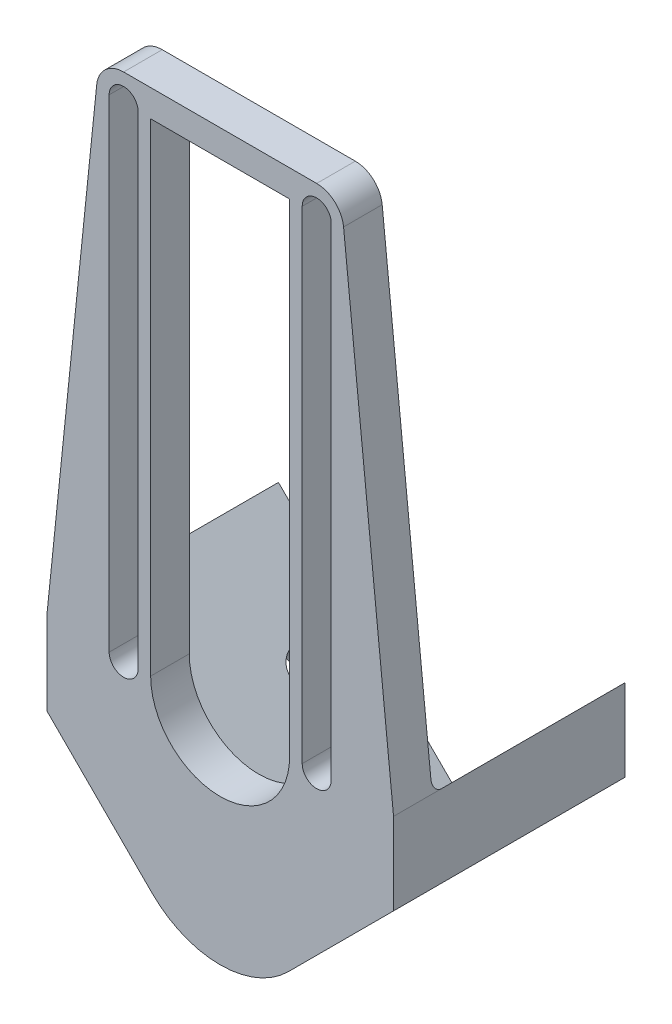
from build123d import *

# Parameters (mm, degrees)
SALIENTE_EXTRUIR1_DEPTH = 20
SALIENTE_EXTRUIR2_DEPTH = 4
REDONDEO1_R             = 1
REDONDEO2_R             = 10
CROQUIS3_R              = 1.8
CORTAR_EXTRUIR1_DEPTH   = 6
CROQUIS4_R              = 1.8
CORTAR_EXTRUIR2_DEPTH   = 6
CROQUIS5_R              = 3.2
CORTAR_EXTRUIR3_DEPTH   = 4
CROQUIS6_R              = 3.2
CORTAR_EXTRUIR4_DEPTH   = 4


with BuildPart() as part:
    # Croquis2 → Saliente-Extruir1 (new body)
    with BuildSketch(Plane.XY):
        Polygon((0, 0), (-17.960512242, 17.960512242), (-17.960512242, 9.475230868), (0, -8.485281374), align=None)
        Polygon((0, -8.485281374), (0, 0), (17.960512242, 17.960512242), (17.960512242, 9.475230868), align=None)
    extrude(amount=-SALIENTE_EXTRUIR1_DEPTH)

    # Croquis2_3 → Saliente-Extruir2 (add)
    with BuildSketch(Plane.XY):
        Polygon((0, 0), (-17.960512242, 17.960512242), (-17.960512242, 9.475230868), (0, -8.485281374), align=None)
        with BuildLine():
            Line((-17.960512242, 17.960512242), (0, 0))
            Line((0, 0), (0, 10.760512242))
            ThreePointArc((0, 10.760512242), (-5.091168825, 12.869343418), (-7.2, 17.960512242))
            ThreePointArc((-7.2, 17.960512242), (-10, 15.160512242), (-12.8, 17.960512242))
            Line((-12.8, 17.960512242), (-12.8, 67.960512242))
            ThreePointArc((-12.8, 67.960512242), (-12.796319785, 68.104024126), (-12.785288814, 68.247158756))
            Line((-12.785288814, 68.247158756), (-17.960512242, 17.960512242))
        make_face()
        with BuildLine():
            Line((0, 10.760512242), (0, 0))
            Line((0, 0), (17.960512242, 17.960512242))
            Line((17.960512242, 17.960512242), (12.785288814, 68.247158756))
            ThreePointArc((12.785288814, 68.247158756), (12.796319785, 68.104024126), (12.8, 67.960512242))
            Line((12.8, 67.960512242), (12.8, 17.960512242))
            ThreePointArc((12.8, 17.960512242), (10, 15.160512242), (7.2, 17.960512242))
            ThreePointArc((7.2, 17.960512242), (5.091168825, 12.869343418), (0, 10.760512242))
        make_face()
        Polygon((0, -8.485281374), (0, 0), (17.960512242, 17.960512242), (17.960512242, 9.475230868), align=None)
        with BuildLine():
            Line((12.8, 67.960512242), (12.8, 17.960512242))
            ThreePointArc((12.8, 17.960512242), (10, 15.160512242), (7.2, 17.960512242))
            Line((7.2, 17.960512242), (7.2, 67.960512242))
            ThreePointArc((7.2, 67.960512242), (10, 70.760512242), (12.8, 67.960512242))
        make_face()
        with BuildLine():
            ThreePointArc((11.5, 67.960512242), (10, 69.460512242), (8.5, 67.960512242))
            Line((8.5, 67.960512242), (8.5, 17.960512242))
            ThreePointArc((8.5, 17.960512242), (10, 16.460512242), (11.5, 17.960512242))
            Line((11.5, 17.960512242), (11.5, 67.960512242))
        make_face(mode=Mode.SUBTRACT)
        with BuildLine():
            ThreePointArc((-12.8, 67.960512242), (-10, 70.760512242), (-7.2, 67.960512242))
            Line((-7.2, 67.960512242), (-7.2, 17.960512242))
            ThreePointArc((-7.2, 17.960512242), (-10, 15.160512242), (-12.8, 17.960512242))
            Line((-12.8, 17.960512242), (-12.8, 67.960512242))
        make_face()
        with BuildLine():
            Line((-11.5, 67.960512242), (-11.5, 17.960512242))
            ThreePointArc((-11.5, 17.960512242), (-10, 16.460512242), (-8.5, 17.960512242))
            Line((-8.5, 17.960512242), (-8.5, 67.960512242))
            ThreePointArc((-8.5, 67.960512242), (-10, 69.460512242), (-11.5, 67.960512242))
        make_face(mode=Mode.SUBTRACT)
        with BuildLine():
            ThreePointArc((-10, 70.760512242), (-8.020101013, 69.940411229), (-7.2, 67.960512242))
            Line((-7.2, 67.960512242), (0, 67.960512242))
            Line((0, 67.960512242), (0, 70.760512242))
            Line((0, 70.760512242), (-10, 70.760512242))
        make_face()
        with BuildLine():
            ThreePointArc((7.2, 67.960512242), (8.020101013, 69.940411229), (10, 70.760512242))
            Line((10, 70.760512242), (0, 70.760512242))
            Line((0, 70.760512242), (0, 67.960512242))
            Line((0, 67.960512242), (7.2, 67.960512242))
        make_face()
    extrude(amount=SALIENTE_EXTRUIR2_DEPTH)

    # Redondeo1
    redondeo1_edges = [part.edges().sort_by_distance(p)[0] for p in [
        (-8.980256121, 8.980256121, 0),
        (8.980256121, 8.980256121, 0),
    ]]
    fillet(redondeo1_edges, radius=REDONDEO1_R)

    # Redondeo2
    redondeo2_edges = [part.edges().sort_by_distance(p)[0] for p in [
        (0, -8.485281374, -8),
    ]]
    fillet(redondeo2_edges, radius=REDONDEO2_R)

    # Croquis3 → Cortar-Extruir1 (cut)
    with BuildSketch(Plane(origin=(0, 0, 0), x_dir=(0, 0, -1), z_dir=(0.707106781, 0.707106781, 0))):
        with Locations((14, 12.7)):
            Circle(CROQUIS3_R)
    extrude(amount=-CORTAR_EXTRUIR1_DEPTH, mode=Mode.SUBTRACT)

    # Croquis4 → Cortar-Extruir2 (cut)
    with BuildSketch(Plane(origin=(0, 0, 0), x_dir=(0, 0, 1), z_dir=(-0.707106781, 0.707106781, 0))):
        with Locations((-14, 12.7)):
            Circle(CROQUIS4_R)
    extrude(amount=-CORTAR_EXTRUIR2_DEPTH, mode=Mode.SUBTRACT)

    # Croquis5 → Cortar-Extruir3 (cut)
    with BuildSketch(Plane(origin=(4.242640687, -4.242640687, 0), x_dir=(0, 0, -1), z_dir=(0.707106781, -0.707106781, 0))):
        with Locations((14, 12.7)):
            Circle(CROQUIS5_R)
    extrude(amount=-CORTAR_EXTRUIR3_DEPTH, mode=Mode.SUBTRACT)

    # Croquis6 → Cortar-Extruir4 (cut)
    with BuildSketch(Plane(origin=(-4.242640687, -4.242640687, 0), x_dir=(0, 0, 1), z_dir=(-0.707106781, -0.707106781, 0))):
        with Locations((-14, 12.7)):
            Circle(CROQUIS6_R)
    extrude(amount=-CORTAR_EXTRUIR4_DEPTH, mode=Mode.SUBTRACT)


solid = part.part
